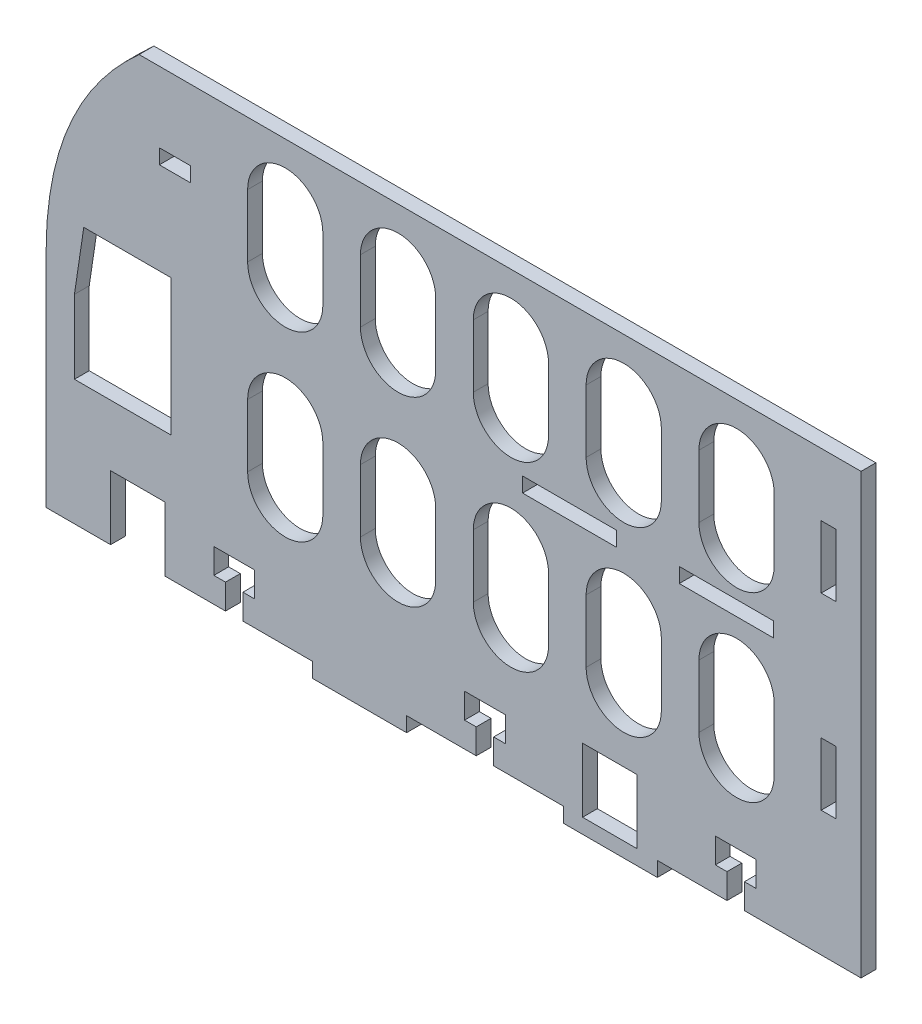
from build123d import *

# Parameters (mm, degrees)
SKETCH1_W           = 3
SKETCH1_H           = 12.7
SKETCH1_W_2         = 6.35
SKETCH1_H_2         = 3
SKETCH1_W_3         = 19.05
SKETCH1_W_4         = 11
SKETCH1_H_3         = 13
BOSS_EXTRUDE1_DEPTH = 3


with BuildPart() as part:
    # Sketch1 → Boss-Extrude1 (new body)
    with BuildSketch(Plane.XY):
        with BuildLine():
            Line((50.8, 31.75), (50.8, -31.75))
            Line((50.8, -31.75), (27.1653, -31.75))
            Line((27.1653, -31.75), (27.1653, -26.67))
            Line((27.1653, -26.67), (29.5275, -26.67))
            Line((29.5275, -26.67), (29.5275, -21.59))
            Line((29.5275, -21.59), (21.2725, -21.59))
            Line((21.2725, -21.59), (21.2725, -26.67))
            Line((21.2725, -26.67), (23.6347, -26.67))
            Line((23.6347, -26.67), (23.6347, -31.75))
            Line((23.6347, -31.75), (9.525, -31.75))
            Line((9.525, -31.75), (9.525, -34.75))
            Line((9.525, -34.75), (-9.525, -34.75))
            Line((-9.525, -34.75), (-9.525, -31.75))
            Line((-9.525, -31.75), (-23.6347, -31.75))
            Line((-23.6347, -31.75), (-23.6347, -26.67))
            Line((-23.6347, -26.67), (-21.2725, -26.67))
            Line((-21.2725, -26.67), (-21.2725, -21.59))
            Line((-21.2725, -21.59), (-29.5275, -21.59))
            Line((-29.5275, -21.59), (-29.5275, -26.67))
            Line((-29.5275, -26.67), (-27.1653, -26.67))
            Line((-27.1653, -26.67), (-27.1653, -31.75))
            Line((-27.1653, -31.75), (-41.275, -31.75))
            Line((-41.275, -31.75), (-41.275, -34.75))
            Line((-41.275, -34.75), (-60.325, -34.75))
            Line((-60.325, -34.75), (-60.325, -31.75))
            Line((-60.325, -31.75), (-74.4347, -31.75))
            Line((-74.4347, -31.75), (-74.4347, -26.67))
            Line((-74.4347, -26.67), (-72.0725, -26.67))
            Line((-72.0725, -26.67), (-72.0725, -21.59))
            Line((-72.0725, -21.59), (-80.3275, -21.59))
            Line((-80.3275, -21.59), (-80.3275, -26.67))
            Line((-80.3275, -26.67), (-77.9653, -26.67))
            Line((-77.9653, -26.67), (-77.9653, -31.75))
            Line((-77.9653, -31.75), (-90.25, -31.75))
            Line((-90.25, -31.75), (-90.25, -18.75))
            Line((-90.25, -18.75), (-101.25, -18.75))
            Line((-101.25, -18.75), (-101.25, -31.75))
            Line((-101.25, -31.75), (-114.3, -31.75))
            Line((-114.3, -31.75), (-114.3, 12.7))
            add(Edge.make_bspline(
                [(-114.3, 12.7), (-114.446449762, 40.172975461), (-95.462376933, 57.15)],
                knots=[0, 0, 0, 1, 1, 1], degree=2))
            Line((-95.462376933, 57.15), (50.8, 57.15))
            Line((50.8, 57.15), (50.8, 31.75))
        make_face()
        with BuildLine():
            Line((33.200035124, 7.62), (33.200035124, -5.08))
            ThreePointArc((33.200035124, -5.08), (25.580035124, -12.7), (17.960035124, -5.08))
            Line((17.960035124, -5.08), (17.960035124, 7.62))
            ThreePointArc((17.960035124, 7.62), (25.580035124, 15.24), (33.200035124, 7.62))
        make_face(mode=Mode.SUBTRACT)
        with Locations((44.22, 38.1)):
            Rectangle(SKETCH1_W, SKETCH1_H, mode=Mode.SUBTRACT)
        with BuildLine():
            Line((10.340035124, 7.62), (10.340035124, -5.08))
            ThreePointArc((10.340035124, -5.08), (2.720035124, -12.7), (-4.899964876, -5.08))
            Line((-4.899964876, -5.08), (-4.899964876, 7.62))
            ThreePointArc((-4.899964876, 7.62), (2.720035124, 15.24), (10.340035124, 7.62))
        make_face(mode=Mode.SUBTRACT)
        with BuildLine():
            Line((-12.519964876, 7.62), (-12.519964876, -5.08))
            ThreePointArc((-12.519964876, -5.08), (-20.139964876, -12.7), (-27.759964876, -5.08))
            Line((-27.759964876, -5.08), (-27.759964876, 7.62))
            ThreePointArc((-27.759964876, 7.62), (-20.139964876, 15.24), (-12.519964876, 7.62))
        make_face(mode=Mode.SUBTRACT)
        with Locations((44.22, 0)):
            Rectangle(SKETCH1_W, SKETCH1_H, mode=Mode.SUBTRACT)
        with BuildLine():
            Line((-35.379964876, 7.62), (-35.379964876, -5.08))
            ThreePointArc((-35.379964876, -5.08), (-42.999964876, -12.7), (-50.619964876, -5.08))
            Line((-50.619964876, -5.08), (-50.619964876, 7.62))
            ThreePointArc((-50.619964876, 7.62), (-42.999964876, 15.24), (-35.379964876, 7.62))
        make_face(mode=Mode.SUBTRACT)
        with BuildLine():
            Line((-58.239964876, 7.62), (-58.239964876, -5.08))
            ThreePointArc((-58.239964876, -5.08), (-65.859964876, -12.7), (-73.479964876, -5.08))
            Line((-73.479964876, -5.08), (-73.479964876, 7.62))
            ThreePointArc((-73.479964876, 7.62), (-65.859964876, 15.24), (-58.239964876, 7.62))
        make_face(mode=Mode.SUBTRACT)
        with BuildLine():
            Line((33.200035124, 44.45), (33.200035124, 31.75))
            ThreePointArc((33.200035124, 31.75), (25.580035124, 24.13), (17.960035124, 31.75))
            Line((17.960035124, 31.75), (17.960035124, 44.45))
            ThreePointArc((17.960035124, 44.45), (25.580035124, 52.07), (33.200035124, 44.45))
        make_face(mode=Mode.SUBTRACT)
        with BuildLine():
            Line((10.340035124, 44.45), (10.340035124, 31.75))
            ThreePointArc((10.340035124, 31.75), (2.720035124, 24.13), (-4.899964876, 31.75))
            Line((-4.899964876, 31.75), (-4.899964876, 44.45))
            ThreePointArc((-4.899964876, 44.45), (2.720035124, 52.07), (10.340035124, 44.45))
        make_face(mode=Mode.SUBTRACT)
        with BuildLine():
            Line((-12.519964876, 44.45), (-12.519964876, 31.75))
            ThreePointArc((-12.519964876, 31.75), (-20.139964876, 24.13), (-27.759964876, 31.75))
            Line((-27.759964876, 31.75), (-27.759964876, 44.45))
            ThreePointArc((-27.759964876, 44.45), (-20.139964876, 52.07), (-12.519964876, 44.45))
        make_face(mode=Mode.SUBTRACT)
        with BuildLine():
            Line((-35.379964876, 44.45), (-35.379964876, 31.75))
            ThreePointArc((-35.379964876, 31.75), (-42.999964876, 24.13), (-50.619964876, 31.75))
            Line((-50.619964876, 31.75), (-50.619964876, 44.45))
            ThreePointArc((-50.619964876, 44.45), (-42.999964876, 52.07), (-35.379964876, 44.45))
        make_face(mode=Mode.SUBTRACT)
        with BuildLine():
            Line((-58.239964876, 44.45), (-58.239964876, 31.75))
            ThreePointArc((-58.239964876, 31.75), (-65.859964876, 24.13), (-73.479964876, 31.75))
            Line((-73.479964876, 31.75), (-73.479964876, 44.45))
            ThreePointArc((-73.479964876, 44.45), (-65.859964876, 52.07), (-58.239964876, 44.45))
        make_face(mode=Mode.SUBTRACT)
        Polygon((-108.570127811, 2.130538697), (-108.570127811, 8.521708079), (-106.677281982, 21.226947449), (-101.67507942, 21.226947449), (-88.964755701, 21.226947449), (-88.964755701, -6.382139969), (-108.570127811, -6.382139969), align=None, mode=Mode.SUBTRACT)
        with Locations((-88.193493425, 41.3464095)):
            Rectangle(SKETCH1_W_2, SKETCH1_H_2, mode=Mode.SUBTRACT)
        with Locations((23.495, 20.550240793)):
            Rectangle(SKETCH1_W_3, SKETCH1_H_2, mode=Mode.SUBTRACT)
        with Locations((-8.255, 20.550240793)):
            Rectangle(SKETCH1_W_3, SKETCH1_H_2, mode=Mode.SUBTRACT)
        with Locations((-0.113307165, -25.25)):
            Rectangle(SKETCH1_W_4, SKETCH1_H_3, mode=Mode.SUBTRACT)
    extrude(amount=BOSS_EXTRUDE1_DEPTH)


solid = part.part
